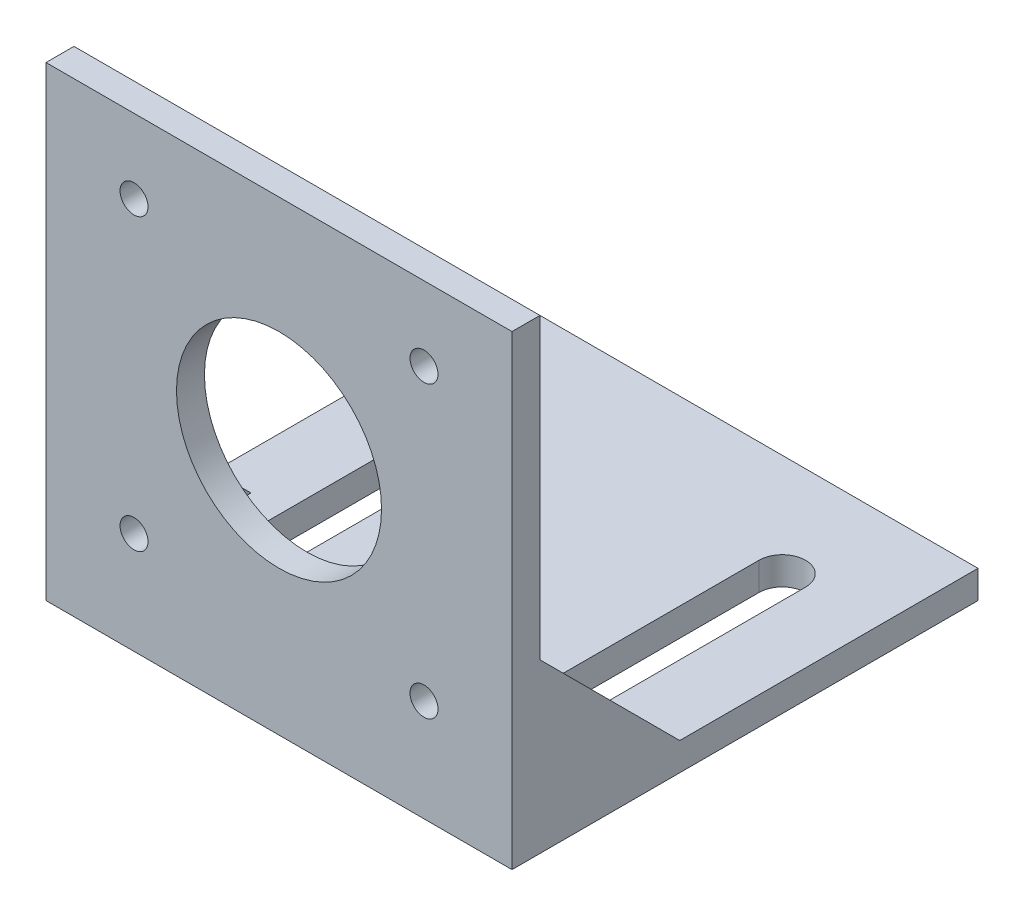
from build123d import *

# Parameters (mm, degrees)
BOSS_EXTRUDE1_DEPTH = 50
SKETCH3_R           = 11
CUT_EXTRUDE1_DEPTH  = 20
CUT_EXTRUDE2_DEPTH  = 4
BOSS_EXTRUDE2_DEPTH = 4
SKETCH7_R           = 1.5
CUT_EXTRUDE3_DEPTH  = 4


with BuildPart() as part:
    # Sketch1 → Boss-Extrude1 (new body)
    with BuildSketch(Plane(origin=(0, 0, 0), x_dir=(0, 0, -1), z_dir=(1, 0, 0))):
        Polygon((0, 0), (0, 50), (3, 50), (3, 3), (50, 3), (50, 0), align=None)
    extrude(amount=BOSS_EXTRUDE1_DEPTH)

    # Sketch3 → Cut-Extrude1 (cut)
    with BuildSketch(Plane(origin=(0, 0, -3), x_dir=(-1, 0, 0), z_dir=(0, 0, -1))):
        with Locations((-25, 26.5)):
            Circle(SKETCH3_R)
    extrude(amount=-CUT_EXTRUDE1_DEPTH, mode=Mode.SUBTRACT)

    # Sketch4 → Cut-Extrude2 (cut, through all)
    with BuildSketch(Plane(origin=(0, 3, 0), x_dir=(1, 0, 0), z_dir=(0, 1, 0))):
        with BuildLine():
            Line((7.5, 14), (7.5, 39))
            ThreePointArc((7.5, 39), (10, 41.5), (12.5, 39))
            Line((12.5, 39), (12.5, 14))
            ThreePointArc((12.5, 14), (10, 11.5), (7.5, 14))
        make_face()
        with BuildLine():
            Line((42.5, 14), (42.5, 39))
            ThreePointArc((42.5, 39), (40, 41.5), (37.5, 39))
            Line((37.5, 39), (37.5, 14))
            ThreePointArc((37.5, 14), (40, 11.5), (42.5, 14))
        make_face()
    extrude(amount=-CUT_EXTRUDE2_DEPTH, mode=Mode.SUBTRACT)

    # Sketch6 → Boss-Extrude2 (add)
    with BuildSketch(Plane(origin=(50, 0, 0), x_dir=(0, 0, -1), z_dir=(1, 0, 0))):
        Polygon((3, 3), (18, 3), (3, 18), align=None)
    boss_extrude2 = extrude(amount=-BOSS_EXTRUDE2_DEPTH)

    # Mirror1: Boss-Extrude2 across plane
    add(boss_extrude2.mirror(Plane(origin=(25, 0, 0), x_dir=(0, 0, 1), z_dir=(1, 0, 0))))

    # Sketch7 → Cut-Extrude3 (cut, through all)
    with BuildSketch(Plane(origin=(0, 0, -3), x_dir=(-1, 0, 0), z_dir=(0, 0, -1))):
        with Locations((-40.556349186, 42.056349186)):
            Circle(SKETCH7_R)
        with Locations((-9.443650814, 42.056349186)):
            Circle(SKETCH7_R)
        with Locations((-40.556349186, 10.943650814)):
            Circle(SKETCH7_R)
        with Locations((-9.443650814, 10.943650814)):
            Circle(SKETCH7_R)
    extrude(amount=-CUT_EXTRUDE3_DEPTH, mode=Mode.SUBTRACT)


solid = part.part
